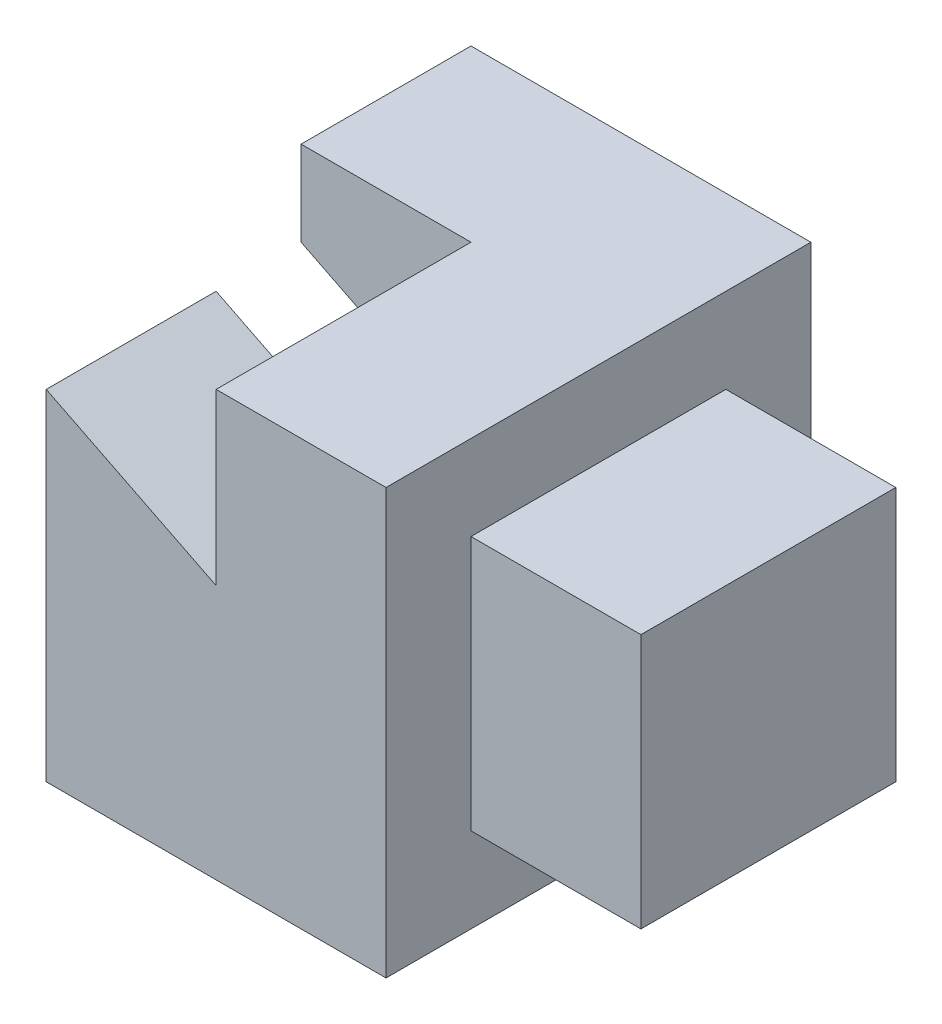
from build123d import *

# Parameters (mm, degrees)
SKETCH1_W           = 3
SKETCH1_H           = 3
BOSS_EXTRUDE1_DEPTH = 2
SKETCH2_W           = 5
SKETCH2_H           = 5
BOSS_EXTRUDE2_DEPTH = 2
BOSS_EXTRUDE3_DEPTH = 2
BOSS_EXTRUDE4_DEPTH = 2


with BuildPart() as part:
    # Sketch1 → Boss-Extrude1 (new body)
    with BuildSketch(Plane(origin=(0, 0, 0), x_dir=(0, 0, -1), z_dir=(1, 0, 0))):
        Rectangle(SKETCH1_W, SKETCH1_H)
    extrude(amount=BOSS_EXTRUDE1_DEPTH)

    # Sketch2 → Boss-Extrude2 (add)
    with BuildSketch(Plane.ZY):
        Rectangle(SKETCH2_W, SKETCH2_H)
    extrude(amount=BOSS_EXTRUDE2_DEPTH)

    # Sketch4 → Boss-Extrude3 (add)
    with BuildSketch(Plane.XY.offset(2.5)):
        Polygon((-2, -2.5), (-4, -2.5), (-4, 1.5), (-2, 0.5), align=None)
    extrude(amount=-BOSS_EXTRUDE3_DEPTH)

    # Sketch5 → Boss-Extrude4 (add)
    with BuildSketch(Plane(origin=(0, 0, -2.5), x_dir=(-1, 0, 0), z_dir=(0, 0, -1))):
        Polygon((2, 2.5), (2, 0.5), (4, 1.5), (4, 2.5), align=None)
    extrude(amount=-BOSS_EXTRUDE4_DEPTH)


solid = part.part
